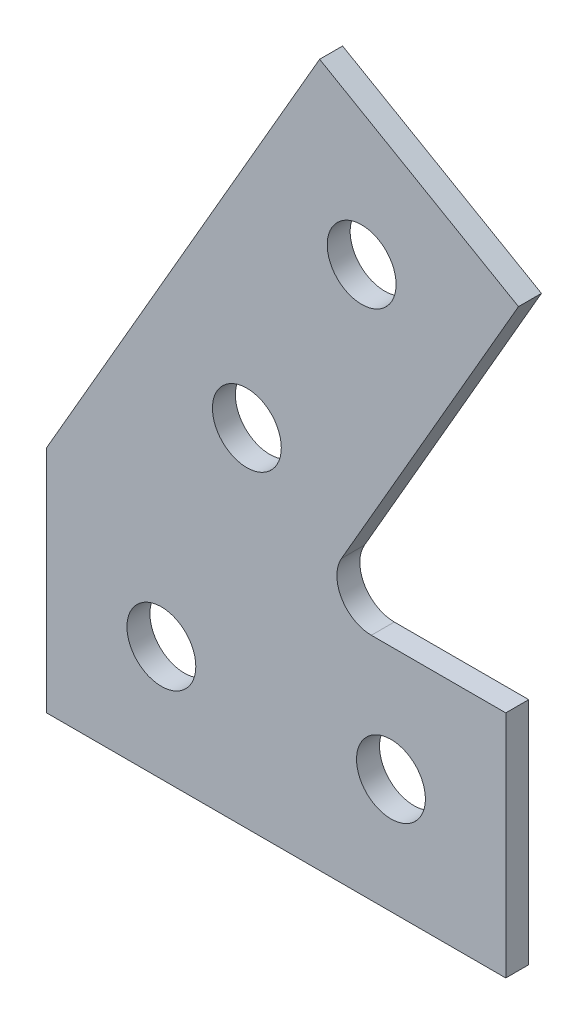
from build123d import *

# Parameters (mm, degrees)
ESQUISSE1_R        = 1.5
BOSS_EXTRU_1_DEPTH = 1


with BuildPart() as part:
    # Esquisse1 → Boss.-Extru.1 (new body)
    with BuildSketch(Plane.XY):
        with BuildLine():
            Line((0, 0), (20, 0))
            Line((20, 0), (20, 10))
            Line((20, 10), (14.145081595, 10))
            ThreePointArc((14.145081595, 10), (12.846043489, 10.75), (12.846043489, 12.25))
            Line((12.846043489, 12.25), (20.553669583, 25.6))
            Line((20.553669583, 25.6), (11.893415545, 30.6))
            Line((11.893415545, 30.6), (0, 10))
            Line((0, 10), (0, 0))
        make_face()
        with Locations((5, 5)):
            Circle(ESQUISSE1_R, mode=Mode.SUBTRACT)
        with Locations((15, 5)):
            Circle(ESQUISSE1_R, mode=Mode.SUBTRACT)
        with Locations((13.723542564, 23.769872981)):
            Circle(ESQUISSE1_R, mode=Mode.SUBTRACT)
        with Locations((8.723542564, 15.109618943)):
            Circle(ESQUISSE1_R, mode=Mode.SUBTRACT)
    extrude(amount=BOSS_EXTRU_1_DEPTH)


solid = part.part
